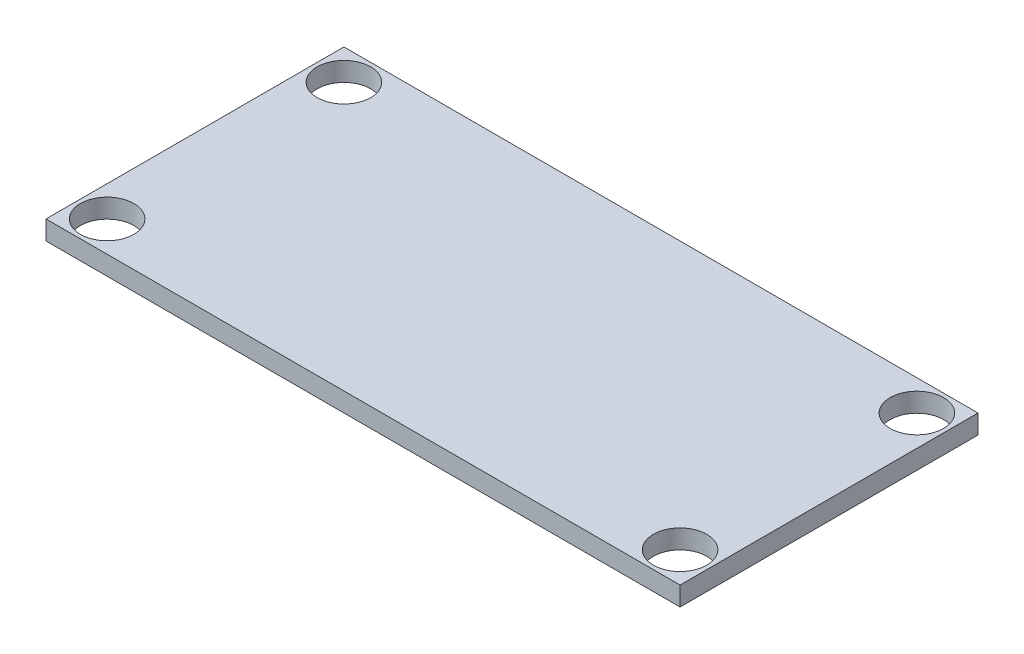
from build123d import *

# Parameters (mm, degrees)
SKETCH1_W           = 83
SKETCH1_H           = 39
SKETCH1_R           = 3.5
BOSS_EXTRUDE1_DEPTH = 2.5


with BuildPart() as part:
    # Sketch1 → Boss-Extrude1 (new body)
    with BuildSketch(Plane(origin=(0, 0, 0), x_dir=(1, 0, 0), z_dir=(0, 1, 0))):
        Rectangle(SKETCH1_W, SKETCH1_H)
        with Locations((37.5, 15.5)):
            Circle(SKETCH1_R, mode=Mode.SUBTRACT)
        with Locations((-37.5, 15.5)):
            Circle(SKETCH1_R, mode=Mode.SUBTRACT)
        with Locations((-37.5, -15.5)):
            Circle(SKETCH1_R, mode=Mode.SUBTRACT)
        with Locations((37.5, -15.5)):
            Circle(SKETCH1_R, mode=Mode.SUBTRACT)
    extrude(amount=BOSS_EXTRUDE1_DEPTH)


solid = part.part
